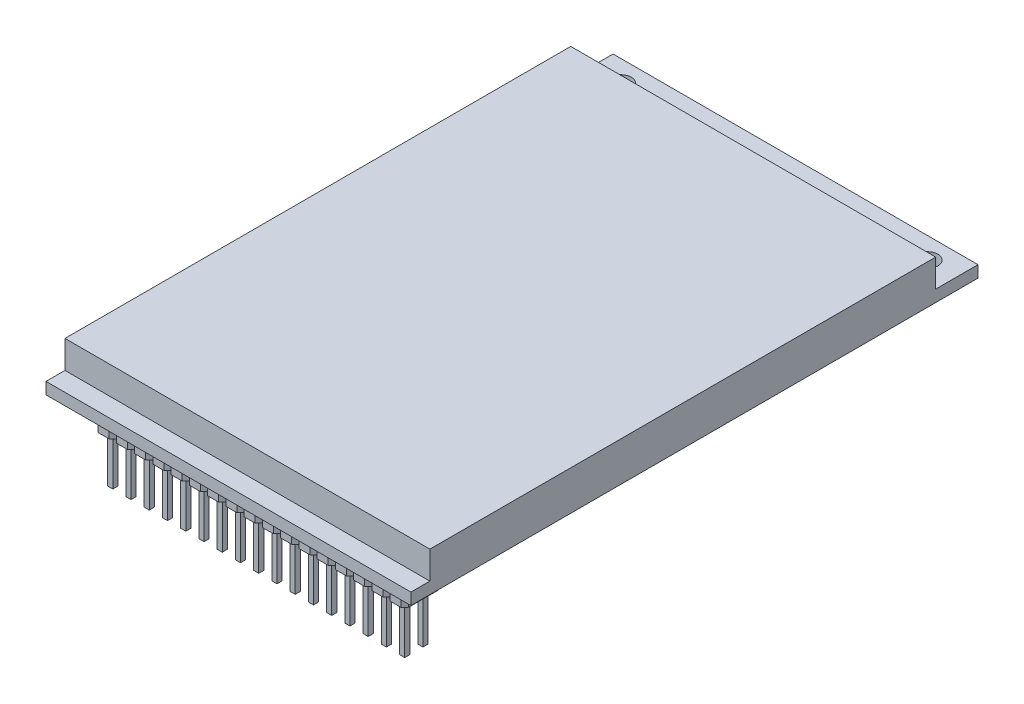
from build123d import *

# Parameters (mm, degrees)
SKETCH_1_W                 = 50
SKETCH_1_H                 = 77.7
SKETCH_1_R                 = 1.4
EXTRUDE_1_DEPTH            = 1.6
SKETCH_2_W                 = 50
SKETCH_2_H                 = 69.3
EXTRUDE_2_DEPTH            = 3.8
EXTRUDE_3_DEPTH            = 3.8
SKETCH_4_W                 = 0.7
SKETCH_4_H                 = 0.7
EXTRUDE_4_DEPTH            = 6.6
PATTERN_LINEAR_2_COUNT     = 9
PATTERN_LINEAR_2_PITCH     = 2.5
PATTERN_LINEAR_2_COL_COUNT = 9
PATTERN_LINEAR_2_COL_PITCH = 2.5


with BuildPart() as part:
    # 草图1 → 凸台-拉伸1 (new body)
    with BuildSketch(Plane(origin=(0, 0, 0), x_dir=(1, 0, 0), z_dir=(0, 1, 0))):
        Rectangle(SKETCH_1_W, SKETCH_1_H)
        with Locations((-21, 35.95)):
            Circle(SKETCH_1_R, mode=Mode.SUBTRACT)
        with Locations((21, 35.95)):
            Circle(SKETCH_1_R, mode=Mode.SUBTRACT)
    extrude(amount=EXTRUDE_1_DEPTH)

    # 草图2 → 凸台-拉伸2 (add)
    with BuildSketch(Plane(origin=(0, 1.6, 0), x_dir=(1, 0, 0), z_dir=(0, 1, 0))):
        with Locations((0, -1.6)):
            Rectangle(SKETCH_2_W, SKETCH_2_H)
    extrude(amount=EXTRUDE_2_DEPTH)

    # 草图3 → 凸台-拉伸3 (add)
    with BuildSketch(Plane.XZ):
        Polygon((1.25, 31.45), (0.75, 30.95), (-0.75, 30.95), (-1.25, 31.45), (-1.25, 35.45), (-0.75, 35.95), (0.75, 35.95), (1.25, 35.45), align=None)
    extrude_3 = extrude(amount=EXTRUDE_3_DEPTH)

    # 草图4 → 凸台-拉伸4 (add)
    with BuildSketch(Plane.XZ.offset(3.8)):
        with Locations((0, 32.2)):
            Rectangle(SKETCH_4_W, SKETCH_4_H)
        with Locations((0, 34.7)):
            Rectangle(SKETCH_4_W, SKETCH_4_H)
    extrude_4 = extrude(amount=EXTRUDE_4_DEPTH)

    # 阵列(线性)2: 凸台-拉伸3, 凸台-拉伸4 ×9
    with Locations(*[(i * PATTERN_LINEAR_2_PITCH, 0, 0) for i in range(1, PATTERN_LINEAR_2_COUNT)]):
        add(extrude_3)
        add(extrude_4)

    # 阵列(线性)2 col: 凸台-拉伸3, 凸台-拉伸4 ×9
    with Locations(*[(-i * PATTERN_LINEAR_2_COL_PITCH, 0, 0) for i in range(1, PATTERN_LINEAR_2_COL_COUNT)]):
        add(extrude_3)
        add(extrude_4)


solid = part.part
